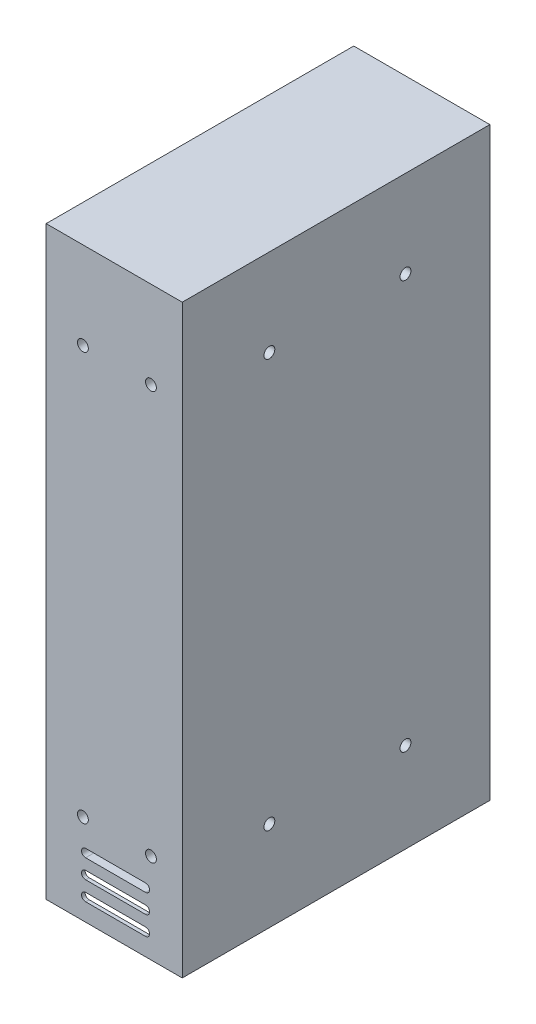
from build123d import *

# Parameters (mm, degrees)
ESBO_O1_W                = 50
ESBO_O1_H                = 215
RESSALTO_EXTRUS_O1_DEPTH = 113
CORTE_EXTRUS_O1_DEPTH    = 113
ESBO_O3_W                = 110.4
ESBO_O3_H                = 20
CORTE_EXTRUS_O2_DEPTH    = 43
ESBO_O4_R                = 2
CORTE_EXTRUS_O3_DEPTH    = 113
ESBO_O5_R                = 2
CORTE_EXTRUS_O4_DEPTH    = 10
ESBO_O6_R                = 2
CORTE_EXTRUS_O5_DEPTH    = 10


with BuildPart() as part:
    # Esboço1 → Ressalto-extrusão1 (new body)
    with BuildSketch(Plane.XY):
        Rectangle(ESBO_O1_W, ESBO_O1_H)
    extrude(amount=RESSALTO_EXTRUS_O1_DEPTH)

    # Esboço2 → Corte-extrusão1 (cut)
    with BuildSketch(Plane(origin=(0, 0, 0), x_dir=(-1, 0, 0), z_dir=(0, 0, -1))):
        with BuildLine():
            Line((-11.5, -98), (10.5, -98))
            ThreePointArc((10.5, -98), (12, -99.5), (10.5, -101))
            Line((10.5, -101), (-11.5, -101))
            ThreePointArc((-11.5, -101), (-13, -99.5), (-11.5, -98))
        make_face()
        with BuildLine():
            Line((-11.5, -91), (10.5, -91))
            ThreePointArc((10.5, -91), (12, -92.5), (10.5, -94))
            Line((10.5, -94), (-11.5, -94))
            ThreePointArc((-11.5, -94), (-13, -92.5), (-11.5, -91))
        make_face()
        with BuildLine():
            Line((-11.5, -84), (10.5, -84))
            ThreePointArc((10.5, -84), (12, -85.5), (10.5, -87))
            Line((10.5, -87), (-11.5, -87))
            ThreePointArc((-11.5, -87), (-13, -85.5), (-11.5, -84))
        make_face()
    extrude(amount=-CORTE_EXTRUS_O1_DEPTH, mode=Mode.SUBTRACT)

    # Esboço3 → Corte-extrusão2 (cut)
    with BuildSketch(Plane.ZY.offset(25)):
        with Locations((56.5, -97.5)):
            Rectangle(ESBO_O3_W, ESBO_O3_H)
    extrude(amount=-CORTE_EXTRUS_O2_DEPTH, mode=Mode.SUBTRACT)

    # Esboço4 → Corte-extrusão3 (cut)
    with BuildSketch(Plane.XY.offset(113)):
        with Locations((13.5, -74.5)):
            Circle(ESBO_O4_R)
        with Locations((13.5, 75.5)):
            Circle(ESBO_O4_R)
    extrude(amount=-CORTE_EXTRUS_O3_DEPTH, mode=Mode.SUBTRACT)

    # Esboço5 → Corte-extrusão4 (cut)
    with BuildSketch(Plane.XY.offset(113)):
        with Locations((-11.5, 75.5)):
            Circle(ESBO_O5_R)
        with Locations((-11.5, -74.5)):
            Circle(ESBO_O5_R)
    extrude(amount=-CORTE_EXTRUS_O4_DEPTH, mode=Mode.SUBTRACT)

    # Esboço6 → Corte-extrusão5 (cut)
    with BuildSketch(Plane(origin=(25, 0, 0), x_dir=(0, 0, -1), z_dir=(1, 0, 0))):
        with Locations((-31, -74.5)):
            Circle(ESBO_O6_R)
        with Locations((-81, -74.5)):
            Circle(ESBO_O6_R)
        with Locations((-31, 75.5)):
            Circle(ESBO_O6_R)
        with Locations((-81, 75.5)):
            Circle(ESBO_O6_R)
    extrude(amount=-CORTE_EXTRUS_O5_DEPTH, mode=Mode.SUBTRACT)


solid = part.part
